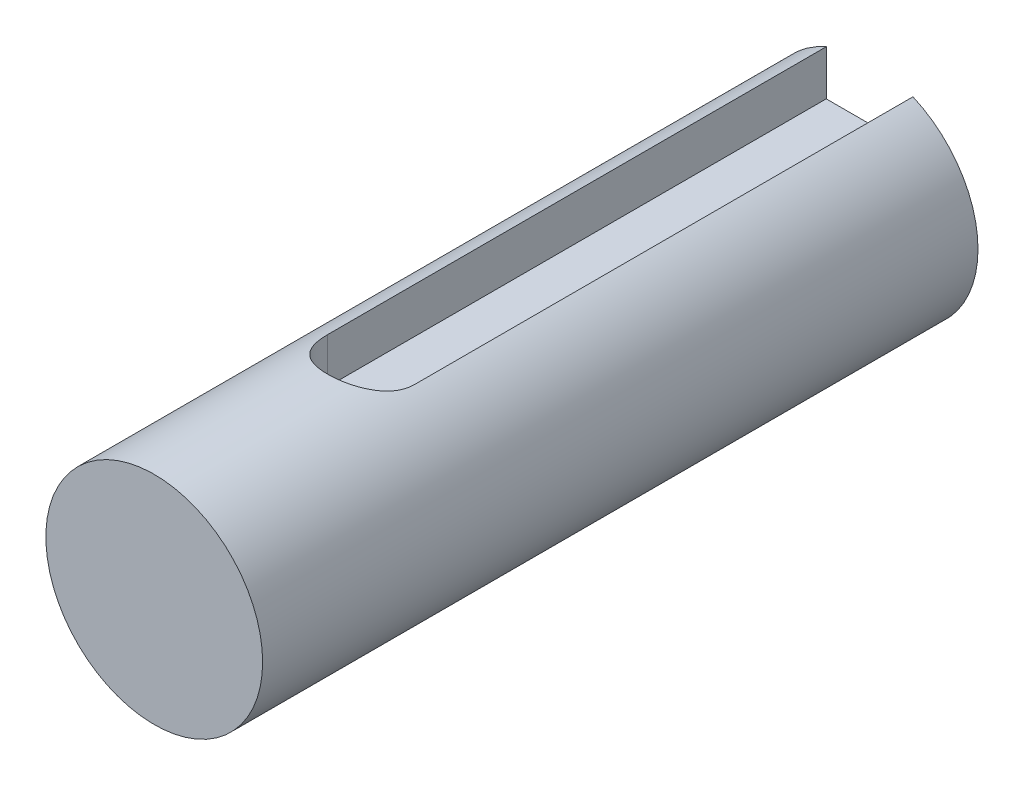
from build123d import *

# Parameters (mm, degrees)
SKETCH2_W           = 60
SKETCH2_H           = 60
BOSS_EXTRUDE1_DEPTH = 42
SKETCH3_W           = 60
SKETCH3_H           = 60
BOSS_EXTRUDE2_DEPTH = 38
FILLET1_R           = 5
FILLET2_R           = 5
FILLET3_R           = 5
SKETCH4_R           = 2.25
CUT_EXTRUDE1_DEPTH  = 10
SKETCH5_R           = 12
BOSS_EXTRUDE3_DEPTH = 4
SKETCH6_R           = 5
BOSS_EXTRUDE4_DEPTH = 28
CUT_EXTRUDE2_DEPTH  = 28
SKETCH8_W           = 83.4072332
SKETCH8_H           = 75.183984856
CUT_EXTRUDE3_DEPTH  = 84
SKETCH9_R           = 5
BOSS_EXTRUDE5_DEPTH = 5


with BuildPart() as part:
    # Sketch2 → Boss-Extrude1 (new body)
    with BuildSketch(Plane.XY):
        with Locations((30, 30)):
            Rectangle(SKETCH2_W, SKETCH2_H)
    extrude(amount=BOSS_EXTRUDE1_DEPTH)

    # Fillet1
    fillet1_edges = [part.edges().sort_by_distance(p)[0] for p in [
        (0, 60, 21),
        (60, 60, 21),
        (60, 0, 21),
        (0, 0, 21),
    ]]
    fillet(fillet1_edges, radius=FILLET1_R)

    # Fillet3
    fillet3_edges = [part.edges().sort_by_distance(p)[0] for p in [
        (30, 0, 42),
        (0, 30, 42),
        (60, 30, 42),
        (30, 60, 42),
        (58.535533906, 58.535533906, 42),
        (1.464466094, 58.535533906, 42),
        (58.535533906, 1.464466094, 42),
        (1.464466094, 1.464466094, 42),
    ]]
    fillet(fillet3_edges, radius=FILLET3_R)


with BuildPart() as body_2:
    # Sketch3 → Boss-Extrude2 (new body)
    with BuildSketch(Plane(origin=(0, 0, 0), x_dir=(-1, 0, 0), z_dir=(0, 0, -1))):
        with Locations((-30, 30)):
            Rectangle(SKETCH3_W, SKETCH3_H)
    extrude(amount=BOSS_EXTRUDE2_DEPTH)

    # Fillet2
    fillet2_edges = [body_2.edges().sort_by_distance(p)[0] for p in [
        (60, 0, -19),
        (60, 60, -19),
        (0, 60, -19),
        (0, 0, -19),
    ]]
    fillet(fillet2_edges, radius=FILLET2_R)

    # Sketch4 → Cut-Extrude1 (cut)
    with BuildSketch(Plane(origin=(0, 0, -38), x_dir=(-1, 0, 0), z_dir=(0, 0, -1))):
        with Locations((-5.251262658, 54.748737342)):
            Circle(SKETCH4_R)
        with Locations((-54.748737342, 54.748737342)):
            Circle(SKETCH4_R)
        with Locations((-54.748737342, 5.251262658)):
            Circle(SKETCH4_R)
        with Locations((-5.251262658, 5.251262658)):
            Circle(SKETCH4_R)
    extrude(amount=-CUT_EXTRUDE1_DEPTH, mode=Mode.SUBTRACT)

    # Sketch5 → Boss-Extrude3 (add)
    with BuildSketch(Plane(origin=(0, 0, -38), x_dir=(-1, 0, 0), z_dir=(0, 0, -1))):
        with Locations((-30, 40)):
            Circle(SKETCH5_R)
    extrude(amount=BOSS_EXTRUDE3_DEPTH)

    # Sketch6 → Boss-Extrude4 (add)
    with BuildSketch(Plane(origin=(0, 0, -42), x_dir=(-1, 0, 0), z_dir=(0, 0, -1))):
        with Locations((-30, 40)):
            Circle(SKETCH6_R)
    extrude(amount=BOSS_EXTRUDE4_DEPTH)

    # Sketch7 → Cut-Extrude2 (cut)
    with BuildSketch(Plane(origin=(0, 42.5, 0), x_dir=(1, 0, 0), z_dir=(0, 1, 0))):
        with BuildLine():
            Line((28, 47), (28, 70))
            Line((28, 70), (32, 70))
            Line((32, 70), (32, 47))
            ThreePointArc((32, 47), (30, 45), (28, 47))
        make_face()
    extrude(amount=CUT_EXTRUDE2_DEPTH, mode=Mode.SUBTRACT)


with BuildPart() as cut_extrude3_tool:
    # Sketch8 → Cut-Extrude3 (new body)
    with BuildSketch(Plane(origin=(0, 0, -42), x_dir=(-1, 0, 0), z_dir=(0, 0, -1))):
        with Locations((-33.52424929, 30.998537299)):
            Rectangle(SKETCH8_W, SKETCH8_H)
    extrude(amount=-CUT_EXTRUDE3_DEPTH)


with BuildPart() as part_1:
    add(part.part)

    # Cut-Extrude3: cut by cut_extrude3_tool
    add(cut_extrude3_tool.part, mode=Mode.SUBTRACT)


with BuildPart() as body_2_1:
    add(body_2.part)

    # Cut-Extrude3: cut by cut_extrude3_tool
    add(cut_extrude3_tool.part, mode=Mode.SUBTRACT)

    # Sketch9 → Boss-Extrude5 (add)
    with BuildSketch(Plane.XY.offset(-42)):
        with Locations((30, 40)):
            Circle(SKETCH9_R)
    extrude(amount=BOSS_EXTRUDE5_DEPTH)


solid = body_2_1.part
